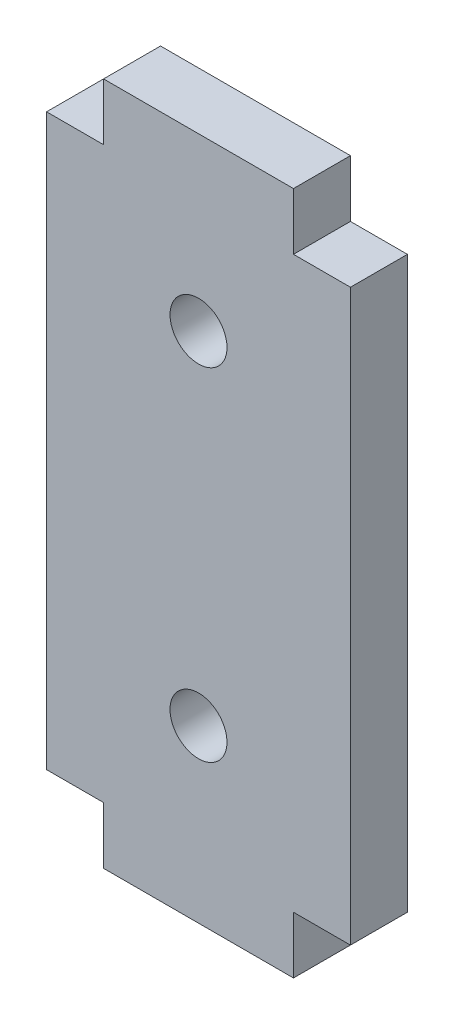
from build123d import *

# Parameters (mm, degrees)
SKETCH1_R           = 1.5
BOSS_EXTRUDE1_DEPTH = 3


with BuildPart() as part:
    # Sketch1 → Boss-Extrude1 (new body)
    with BuildSketch(Plane.XY):
        Polygon((-5, 18), (5, 18), (5, 15), (8, 15), (8, -15), (5, -15), (5, -18), (-5, -18), (-5, -15), (-8, -15), (-8, 15), (-5, 15), align=None)
        with Locations((0, 9)):
            Circle(SKETCH1_R, mode=Mode.SUBTRACT)
        with Locations((0, -9)):
            Circle(SKETCH1_R, mode=Mode.SUBTRACT)
    extrude(amount=BOSS_EXTRUDE1_DEPTH)


solid = part.part
